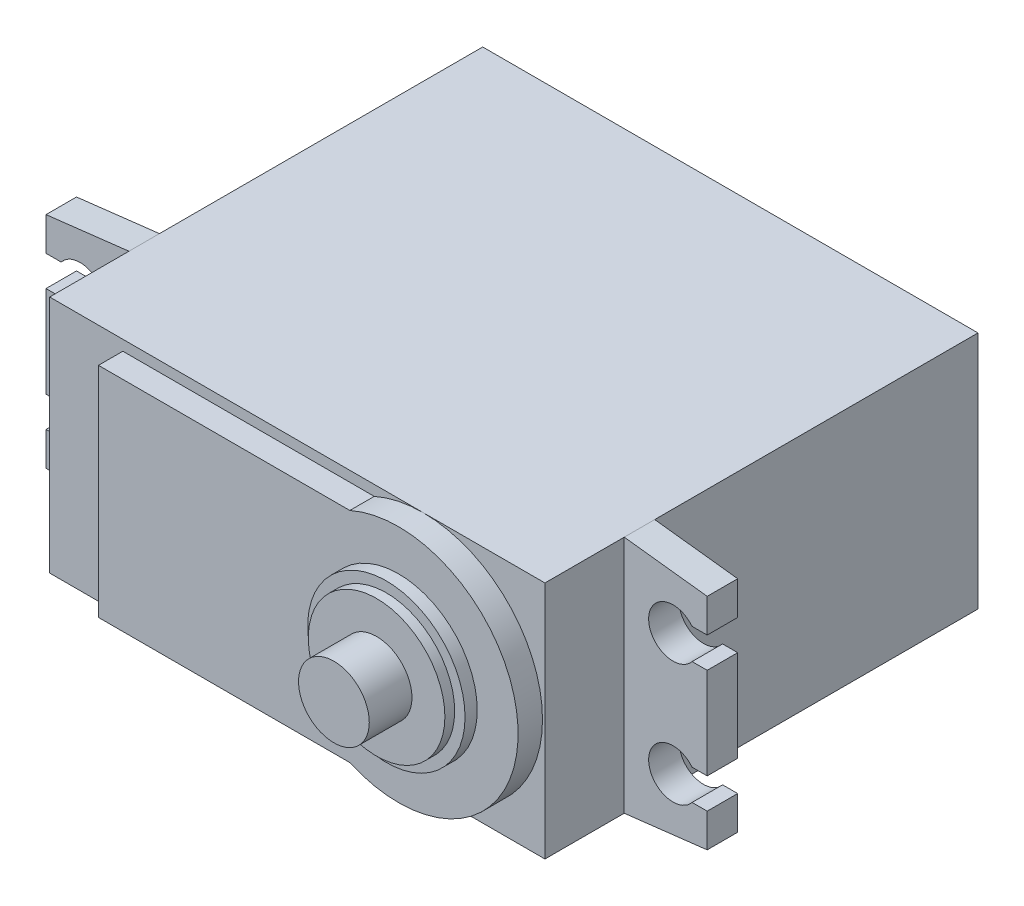
from build123d import *

# Parameters (mm, degrees)
SKETCH_1_W          = 40.6
SKETCH_1_H          = 19.6
EXTRUDE_1_DEPTH     = 35.5
SKETCH_2_R          = 9.8
EXTRUDE_2_DEPTH     = 2
SKETCH_3_W          = 20.607820144
SKETCH_3_H          = 17.9
EXTRUDE_3_DEPTH     = 2
SKETCH_4_R          = 6.45
EXTRUDE_4_DEPTH     = 1
SKETCH_5_R          = 5.6
EXTRUDE_5_DEPTH     = 0.8
SKETCH_7_R          = 2.9
EXTRUDE_6_DEPTH     = 3.5
EXTRUDE_7_DEPTH     = 2.5
CUT_EXTRUDE_1_REACH = 31
SKETCH_9_R          = 2
CUT_EXTRUDE_2_REACH = 31
SKETCH_10_W         = 1.6
SKETCH_10_H         = 2.5


with BuildPart() as part:
    # ｽｹｯﾁ1 → ﾎﾞｽ - 押し出し1 (new body)
    with BuildSketch(Plane.XY):
        with Locations((20.3, 9.8)):
            Rectangle(SKETCH_1_W, SKETCH_1_H)
    extrude(amount=EXTRUDE_1_DEPTH)

    # ｽｹｯﾁ2 → ﾎﾞｽ - 押し出し2 (add)
    with BuildSketch(Plane.XY.offset(35.5)):
        with Locations((30.6, 9.8)):
            Circle(SKETCH_2_R)
    extrude(amount=EXTRUDE_2_DEPTH)

    # ｽｹｯﾁ3 → ﾎﾞｽ - 押し出し3 (add)
    with BuildSketch(Plane.XY.offset(35.5)):
        with Locations((16.303910072, 9.8)):
            Rectangle(SKETCH_3_W, SKETCH_3_H)
    extrude(amount=EXTRUDE_3_DEPTH)

    # ｽｹｯﾁ4 → ﾎﾞｽ - 押し出し4 (add)
    with BuildSketch(Plane.XY.offset(37.5)):
        with Locations((30.6, 9.8)):
            Circle(SKETCH_4_R)
    extrude(amount=EXTRUDE_4_DEPTH)

    # ｽｹｯﾁ5 → ﾎﾞｽ - 押し出し5 (add)
    with BuildSketch(Plane.XY.offset(38.5)):
        with Locations((30.6, 9.8)):
            Circle(SKETCH_5_R)
    extrude(amount=EXTRUDE_5_DEPTH)

    # ｽｹｯﾁ7 → ﾎﾞｽ - 押し出し6 (add)
    with BuildSketch(Plane.XY.offset(39.3)):
        with Locations((30.6, 9.8)):
            Circle(SKETCH_7_R)
    extrude(amount=EXTRUDE_6_DEPTH)

    # ｽｹｯﾁ8 → ﾎﾞｽ - 押し出し7 (add)
    with BuildSketch(Plane.XY.offset(26.5)):
        Polygon((0, 0), (-6.8, 0.8), (-6.8, 18.8), (0, 19.6), align=None)
        Polygon((40.6, 19.6), (40.6, 0), (47.4, 0.8), (47.4, 18.8), align=None)
    extrude(amount=EXTRUDE_7_DEPTH)

    # ｽｹｯﾁ9 → ｶｯﾄ - 押し出し1 (cut, up to next)
    with BuildSketch(Plane.XY.offset(29), mode=Mode.PRIVATE) as cut_extrude_1_sk1:
        with Locations((-4, 4.8)):
            Circle(SKETCH_9_R)
    cut_extrude_1_tool1 = extrude(cut_extrude_1_sk1.sketch, amount=-CUT_EXTRUDE_1_REACH, mode=Mode.PRIVATE) & part.part
    add(cut_extrude_1_tool1.solids().sort_by_distance((-4, 4.8, 29))[0], mode=Mode.SUBTRACT)
    # ｽｹｯﾁ9 → ｶｯﾄ - 押し出し1 (cut, up to next)
    with BuildSketch(Plane.XY.offset(29), mode=Mode.PRIVATE) as cut_extrude_1_sk2:
        with Locations((-4, 14.8)):
            Circle(SKETCH_9_R)
    cut_extrude_1_tool2 = extrude(cut_extrude_1_sk2.sketch, amount=-CUT_EXTRUDE_1_REACH, mode=Mode.PRIVATE) & part.part
    add(cut_extrude_1_tool2.solids().sort_by_distance((-4, 14.8, 29))[0], mode=Mode.SUBTRACT)
    # ｽｹｯﾁ9 → ｶｯﾄ - 押し出し1 (cut, up to next)
    with BuildSketch(Plane.XY.offset(29), mode=Mode.PRIVATE) as cut_extrude_1_sk3:
        with Locations((44.6, 14.8)):
            Circle(SKETCH_9_R)
    cut_extrude_1_tool3 = extrude(cut_extrude_1_sk3.sketch, amount=-CUT_EXTRUDE_1_REACH, mode=Mode.PRIVATE) & part.part
    add(cut_extrude_1_tool3.solids().sort_by_distance((44.6, 14.8, 29))[0], mode=Mode.SUBTRACT)
    # ｽｹｯﾁ9 → ｶｯﾄ - 押し出し1 (cut, up to next)
    with BuildSketch(Plane.XY.offset(29), mode=Mode.PRIVATE) as cut_extrude_1_sk4:
        with Locations((44.6, 4.8)):
            Circle(SKETCH_9_R)
    cut_extrude_1_tool4 = extrude(cut_extrude_1_sk4.sketch, amount=-CUT_EXTRUDE_1_REACH, mode=Mode.PRIVATE) & part.part
    add(cut_extrude_1_tool4.solids().sort_by_distance((44.6, 4.8, 29))[0], mode=Mode.SUBTRACT)

    # ｽｹｯﾁ10 → ｶｯﾄ - 押し出し2 (cut, up to next)
    with BuildSketch(Plane.XY.offset(29), mode=Mode.PRIVATE) as cut_extrude_2_sk1:
        with Locations((-6, 4.8)):
            Rectangle(SKETCH_10_W, SKETCH_10_H)
    cut_extrude_2_tool1 = extrude(cut_extrude_2_sk1.sketch, amount=-CUT_EXTRUDE_2_REACH, mode=Mode.PRIVATE) & part.part
    add(cut_extrude_2_tool1.solids().sort_by_distance((-6, 4.8, 29))[0], mode=Mode.SUBTRACT)
    # ｽｹｯﾁ10 → ｶｯﾄ - 押し出し2 (cut, up to next)
    with BuildSketch(Plane.XY.offset(29), mode=Mode.PRIVATE) as cut_extrude_2_sk2:
        with Locations((-6, 14.8)):
            Rectangle(SKETCH_10_W, SKETCH_10_H)
    cut_extrude_2_tool2 = extrude(cut_extrude_2_sk2.sketch, amount=-CUT_EXTRUDE_2_REACH, mode=Mode.PRIVATE) & part.part
    add(cut_extrude_2_tool2.solids().sort_by_distance((-6, 14.8, 29))[0], mode=Mode.SUBTRACT)
    # ｽｹｯﾁ10 → ｶｯﾄ - 押し出し2 (cut, up to next)
    with BuildSketch(Plane.XY.offset(29), mode=Mode.PRIVATE) as cut_extrude_2_sk3:
        with Locations((46.6, 14.8)):
            Rectangle(SKETCH_10_W, SKETCH_10_H)
    cut_extrude_2_tool3 = extrude(cut_extrude_2_sk3.sketch, amount=-CUT_EXTRUDE_2_REACH, mode=Mode.PRIVATE) & part.part
    add(cut_extrude_2_tool3.solids().sort_by_distance((46.6, 14.8, 29))[0], mode=Mode.SUBTRACT)
    # ｽｹｯﾁ10 → ｶｯﾄ - 押し出し2 (cut, up to next)
    with BuildSketch(Plane.XY.offset(29), mode=Mode.PRIVATE) as cut_extrude_2_sk4:
        with Locations((46.6, 4.8)):
            Rectangle(SKETCH_10_W, SKETCH_10_H)
    cut_extrude_2_tool4 = extrude(cut_extrude_2_sk4.sketch, amount=-CUT_EXTRUDE_2_REACH, mode=Mode.PRIVATE) & part.part
    add(cut_extrude_2_tool4.solids().sort_by_distance((46.6, 4.8, 29))[0], mode=Mode.SUBTRACT)


solid = part.part
